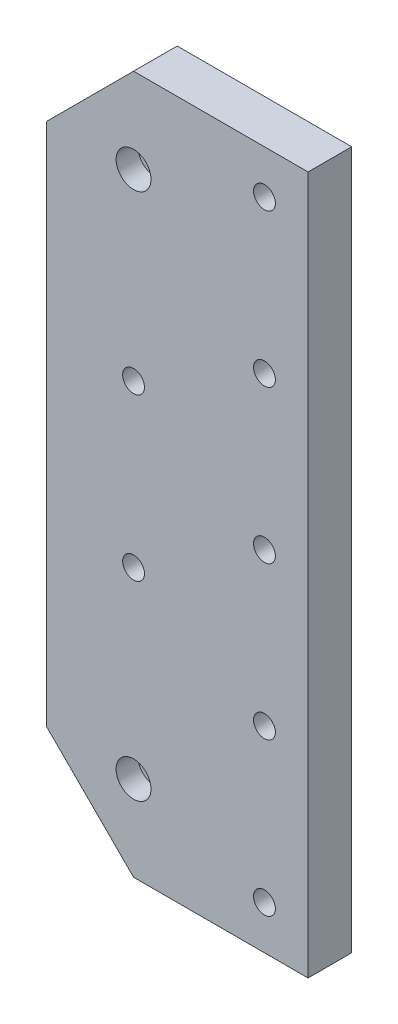
from build123d import *

# Parameters (mm, degrees)
ESBO_O1_R                = 2.500003623
ESBO_O1_R_2              = 2.499998411
ESBO_O1_R_3              = 2.500000084
ESBO_O1_R_4              = 2.500000523
ESBO_O1_R_5              = 2.500001341
ESBO_O1_R_6              = 2.499999924
ESBO_O1_R_7              = 2.500000177
ESBO_O1_R_8              = 4
RESSALTO_EXTRUS_O1_DEPTH = 10
ESBO_O2_R                = 4
RESSALTO_EXTRUS_O2_DEPTH = 5


with BuildPart() as part:
    # Esboço1 → Ressalto-extrusão1 (new body)
    with BuildSketch(Plane.XY):
        Polygon((0.059999999, 112.560092658), (0.059999999, -47.439905629), (-39.939999107, -47.439905629), (-59.93999866, -27.439906076), (-59.93999866, 92.560094967), (-39.94000097, 112.560092658), align=None)
        with Locations((-9.939999778, 102.560092881)):
            Circle(ESBO_O1_R, mode=Mode.SUBTRACT)
        with Locations((-9.939999778, 67.560092732)):
            Circle(ESBO_O1_R_2, mode=Mode.SUBTRACT)
        with Locations((-9.939999778, 32.560099544)):
            Circle(ESBO_O1_R_3, mode=Mode.SUBTRACT)
        with Locations((-39.939999107, 51.060092822)):
            Circle(ESBO_O1_R_4, mode=Mode.SUBTRACT)
        with Locations((-39.939999107, 14.06009607)):
            Circle(ESBO_O1_R_5, mode=Mode.SUBTRACT)
        with Locations((-9.939997915, -2.439905703)):
            Circle(ESBO_O1_R_6, mode=Mode.SUBTRACT)
        with Locations((-9.939997915, -37.439905619)):
            Circle(ESBO_O1_R_7, mode=Mode.SUBTRACT)
        with Locations((-39.939999107, -27.93990393)):
            Circle(ESBO_O1_R_8, mode=Mode.SUBTRACT)
        with Locations((-39.94001777, 93.060093764)):
            Circle(ESBO_O1_R_8, mode=Mode.SUBTRACT)
    extrude(amount=RESSALTO_EXTRUS_O1_DEPTH)

    # Esboço2 → Ressalto-extrusão2 (add)
    with BuildSketch(Plane(origin=(0, 0, 0), x_dir=(-1, 0, 0), z_dir=(0, 0, -1))):
        with Locations((39.94001777, 93.060093764)):
            Circle(ESBO_O2_R)
        with Locations((39.939999107, -27.93990393)):
            Circle(ESBO_O2_R)
    extrude(amount=-RESSALTO_EXTRUS_O2_DEPTH)


solid = part.part
